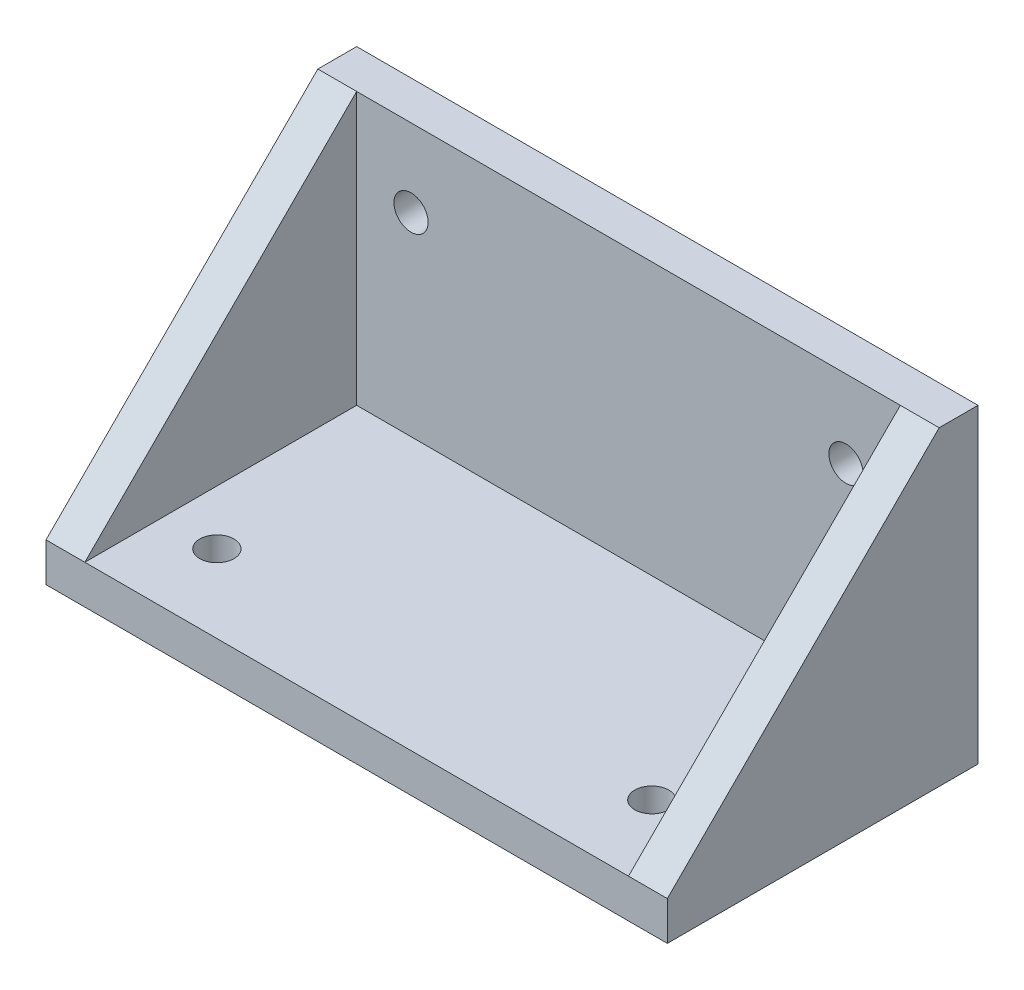
from build123d import *

# Parameters (mm, degrees)
SKETCH1_W           = 80
SKETCH1_H           = 40
BOSS_EXTRUDE1_DEPTH = 5
SKETCH2_W           = 80
SKETCH2_H           = 5
BOSS_EXTRUDE2_DEPTH = 35
BOSS_EXTRUDE3_DEPTH = 5
BOSS_EXTRUDE4_DEPTH = 5
SKETCH5_R           = 2.2
CUT_EXTRUDE1_DEPTH  = 6
SKETCH6_R           = 2.2
CUT_EXTRUDE2_DEPTH  = 6


with BuildPart() as part:
    # Sketch1 → Boss-Extrude1 (new body)
    with BuildSketch(Plane(origin=(0, 0, 0), x_dir=(1, 0, 0), z_dir=(0, 1, 0))):
        Rectangle(SKETCH1_W, SKETCH1_H)
    extrude(amount=BOSS_EXTRUDE1_DEPTH)

    # Sketch2 → Boss-Extrude2 (add)
    with BuildSketch(Plane(origin=(0, 5, 0), x_dir=(1, 0, 0), z_dir=(0, 1, 0))):
        with Locations((0, 17.5)):
            Rectangle(SKETCH2_W, SKETCH2_H)
    extrude(amount=BOSS_EXTRUDE2_DEPTH)

    # Sketch3 → Boss-Extrude3 (add)
    with BuildSketch(Plane.ZY.offset(40)):
        Polygon((-15, 40), (20, 5), (-15, 5), align=None)
    extrude(amount=-BOSS_EXTRUDE3_DEPTH)

    # Sketch4 → Boss-Extrude4 (add)
    with BuildSketch(Plane(origin=(40, 0, 0), x_dir=(0, 0, -1), z_dir=(1, 0, 0))):
        Polygon((15, 40), (-20, 5), (15, 5), align=None)
    extrude(amount=-BOSS_EXTRUDE4_DEPTH)

    # Sketch5 → Cut-Extrude1 (cut, through all)
    with BuildSketch(Plane(origin=(0, 5, 0), x_dir=(1, 0, 0), z_dir=(0, 1, 0))):
        with Locations((-28, -10)):
            Circle(SKETCH5_R)
        with Locations((28, -10)):
            Circle(SKETCH5_R)
    extrude(amount=-CUT_EXTRUDE1_DEPTH, mode=Mode.SUBTRACT)

    # Sketch6 → Cut-Extrude2 (cut, through all)
    with BuildSketch(Plane.XY.offset(-15)):
        with Locations((-28, 30)):
            Circle(SKETCH6_R)
        with Locations((28, 30)):
            Circle(SKETCH6_R)
    extrude(amount=-CUT_EXTRUDE2_DEPTH, mode=Mode.SUBTRACT)


solid = part.part
